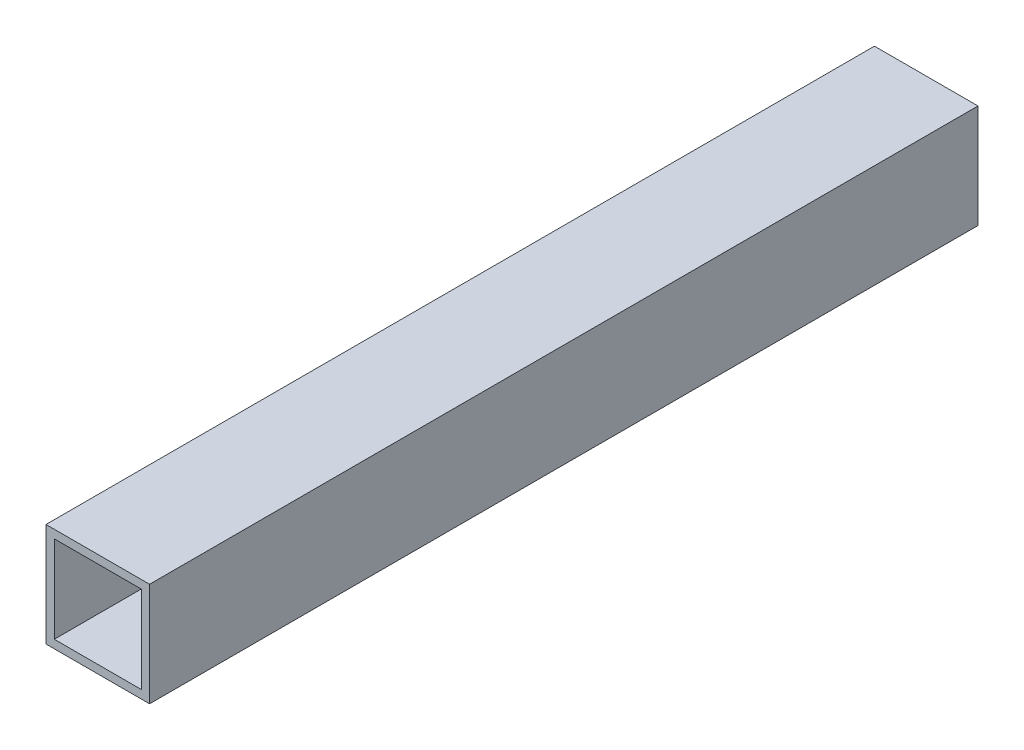
from build123d import *

# Parameters (mm, degrees)
SKETCH2_W           = 38.1
SKETCH2_H           = 38.1
SKETCH2_W_2         = 32.004
SKETCH2_H_2         = 32.004
BOSS_EXTRUDE1_DEPTH = 304.8


with BuildPart() as part:
    # Sketch2 → Boss-Extrude1 (new body)
    with BuildSketch(Plane.XY):
        Rectangle(SKETCH2_W, SKETCH2_H)
        Rectangle(SKETCH2_W_2, SKETCH2_H_2, mode=Mode.SUBTRACT)
    extrude(amount=BOSS_EXTRUDE1_DEPTH)


solid = part.part
